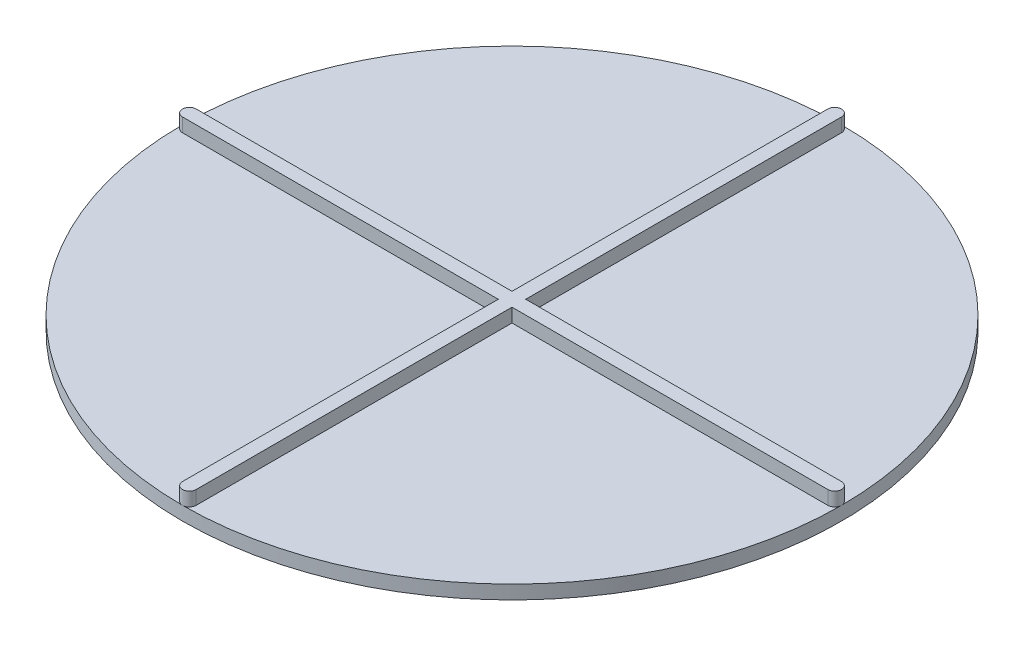
from build123d import *

# Parameters (mm, degrees)
SKETCH1_R           = 76.2
BOSS_EXTRUDE1_DEPTH = 3.175
BOSS_EXTRUDE2_DEPTH = 3.175


with BuildPart() as part:
    # Sketch1 → Boss-Extrude1 (new body)
    with BuildSketch(Plane(origin=(0, 0, 0), x_dir=(1, 0, 0), z_dir=(0, 1, 0))):
        Circle(SKETCH1_R)
    extrude(amount=BOSS_EXTRUDE1_DEPTH)

    # Sketch2 → Boss-Extrude2 (add)
    with BuildSketch(Plane(origin=(0, 3.175, 0), x_dir=(1, 0, 0), z_dir=(0, 1, 0))):
        with BuildLine():
            Line((-74.6125, 1.5875), (74.6125, 1.5875))
            ThreePointArc((74.6125, 1.5875), (76.2, 0), (74.6125, -1.5875))
            Line((74.6125, -1.5875), (-74.6125, -1.5875))
            ThreePointArc((-74.6125, -1.5875), (-76.2, 0), (-74.6125, 1.5875))
        make_face()
        with BuildLine():
            Line((1.5875, 74.6125), (1.5875, -74.6125))
            ThreePointArc((1.5875, -74.6125), (0, -76.2), (-1.5875, -74.6125))
            Line((-1.5875, -74.6125), (-1.5875, 74.6125))
            ThreePointArc((-1.5875, 74.6125), (0, 76.2), (1.5875, 74.6125))
        make_face()
    extrude(amount=BOSS_EXTRUDE2_DEPTH)


solid = part.part
